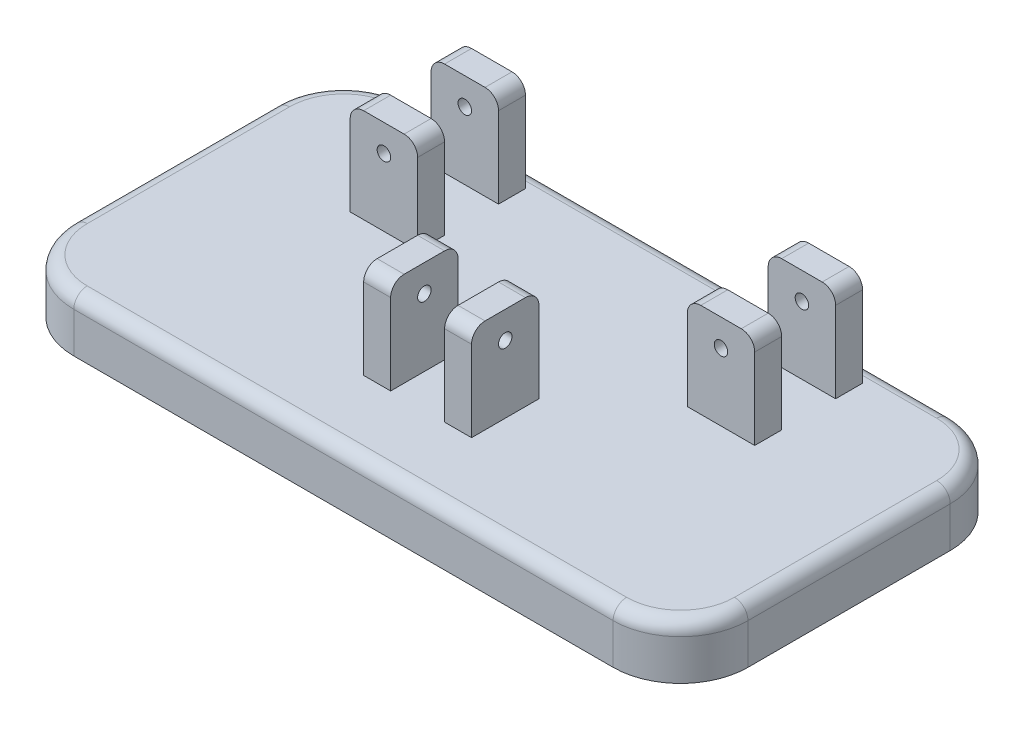
from build123d import *

# Parameters (mm, degrees)
BOSS_EXTRUDE1_DEPTH = 8
SKETCH4_W           = 10
SKETCH4_H           = 4
SKETCH4_W_2         = 4
SKETCH4_H_2         = 10
BOSS_EXTRUDE2_DEPTH = 14
SKETCH5_R           = 1
CUT_EXTRUDE1_DEPTH  = 16
SKETCH6_R           = 1
CUT_EXTRUDE2_DEPTH  = 16
FILLET1_R           = 2


with BuildPart() as part:
    # Sketch3 → Boss-Extrude1 (new body)
    with BuildSketch(Plane(origin=(0, 0, 0), x_dir=(1, 0, 0), z_dir=(0, 1, 0))):
        with BuildLine():
            Line((-40, 25), (40, 25))
            ThreePointArc((40, 25), (47.071067812, 22.071067812), (50, 15))
            Line((50, 15), (50, -15))
            ThreePointArc((50, -15), (47.071067812, -22.071067812), (40, -25))
            Line((40, -25), (-40, -25))
            ThreePointArc((-40, -25), (-47.071067812, -22.071067812), (-50, -15))
            Line((-50, -15), (-50, 15))
            ThreePointArc((-50, 15), (-47.071067812, 22.071067812), (-40, 25))
        make_face()
    extrude(amount=BOSS_EXTRUDE1_DEPTH)

    # Sketch4 → Boss-Extrude2 (add)
    with BuildSketch(Plane(origin=(0, 8, 0), x_dir=(1, 0, 0), z_dir=(0, 1, 0))):
        with Locations((-25, 20)):
            Rectangle(SKETCH4_W, SKETCH4_H)
        with Locations((-25, 8)):
            Rectangle(SKETCH4_W, SKETCH4_H)
        with Locations((-6, -9)):
            Rectangle(SKETCH4_W_2, SKETCH4_H_2)
        with Locations((6, -9)):
            Rectangle(SKETCH4_W_2, SKETCH4_H_2)
        with Locations((25, 8)):
            Rectangle(SKETCH4_W, SKETCH4_H)
        with Locations((25, 20)):
            Rectangle(SKETCH4_W, SKETCH4_H)
    extrude(amount=BOSS_EXTRUDE2_DEPTH)

    # Sketch5 → Cut-Extrude1 (cut)
    with BuildSketch(Plane.XY.offset(-6)):
        with Locations((-25, 18)):
            Circle(SKETCH5_R)
        with Locations((25, 18)):
            Circle(SKETCH5_R)
    extrude(amount=-CUT_EXTRUDE1_DEPTH, mode=Mode.SUBTRACT)

    # Sketch6 → Cut-Extrude2 (cut)
    with BuildSketch(Plane.ZY.offset(8)):
        with Locations((9, 18)):
            Circle(SKETCH6_R)
    extrude(amount=-CUT_EXTRUDE2_DEPTH, mode=Mode.SUBTRACT)

    # Fillet1
    fillet1_edges = [part.edges().sort_by_distance(p)[0] for p in [
        (47.071067812, 8, -22.071067812),
        (0, 8, -25),
        (-47.071067812, 8, -22.071067812),
        (-50, 8, 0),
        (-30, 22, -20),
        (-47.071067812, 8, 22.071067812),
        (-20, 22, -20),
        (0, 8, 25),
        (-30, 22, -8),
        (-20, 22, -8),
        (47.071067812, 8, 22.071067812),
        (-6, 22, 14),
        (-6, 22, 4),
        (6, 22, 4),
        (6, 22, 14),
        (30, 22, -8),
        (20, 22, -8),
        (30, 22, -20),
        (20, 22, -20),
        (50, 8, 0),
    ]]
    fillet(fillet1_edges, radius=FILLET1_R)


solid = part.part
